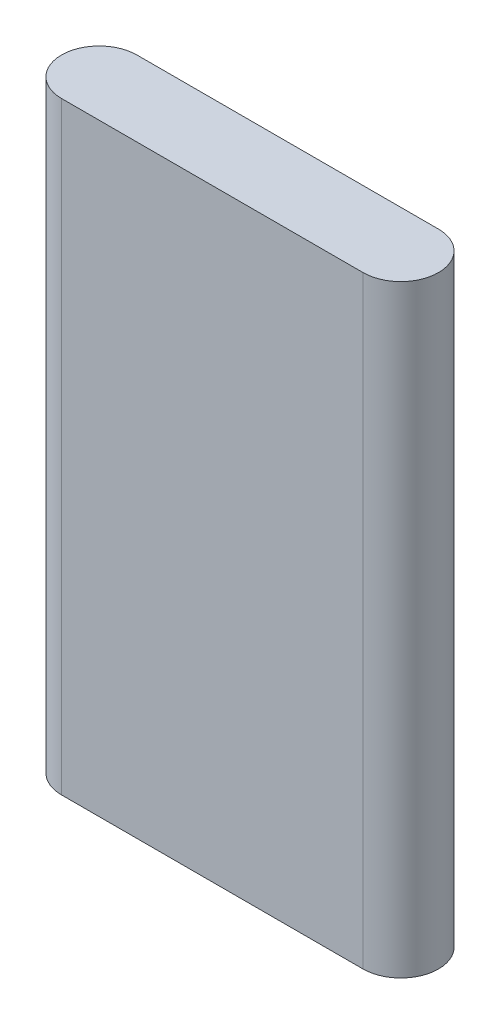
from build123d import *

# Parameters (mm, degrees)
Y_KSEKLIK_EKSTR_ZYON1_DEPTH = 80


with BuildPart() as part:
    # Çizim2 → Yükseklik-Ekstrüzyon1 (new body)
    with BuildSketch(Plane(origin=(0, 0, 0), x_dir=(1, 0, 0), z_dir=(0, 1, 0))):
        with BuildLine():
            Line((-20.314511213, 5), (19.685488787, 5))
            ThreePointArc((19.685488787, 5), (24.685488787, 0), (19.685488787, -5))
            Line((19.685488787, -5), (-20.314511213, -5))
            ThreePointArc((-20.314511213, -5), (-25.314511213, 0), (-20.314511213, 5))
        make_face()
    extrude(amount=Y_KSEKLIK_EKSTR_ZYON1_DEPTH)


solid = part.part
